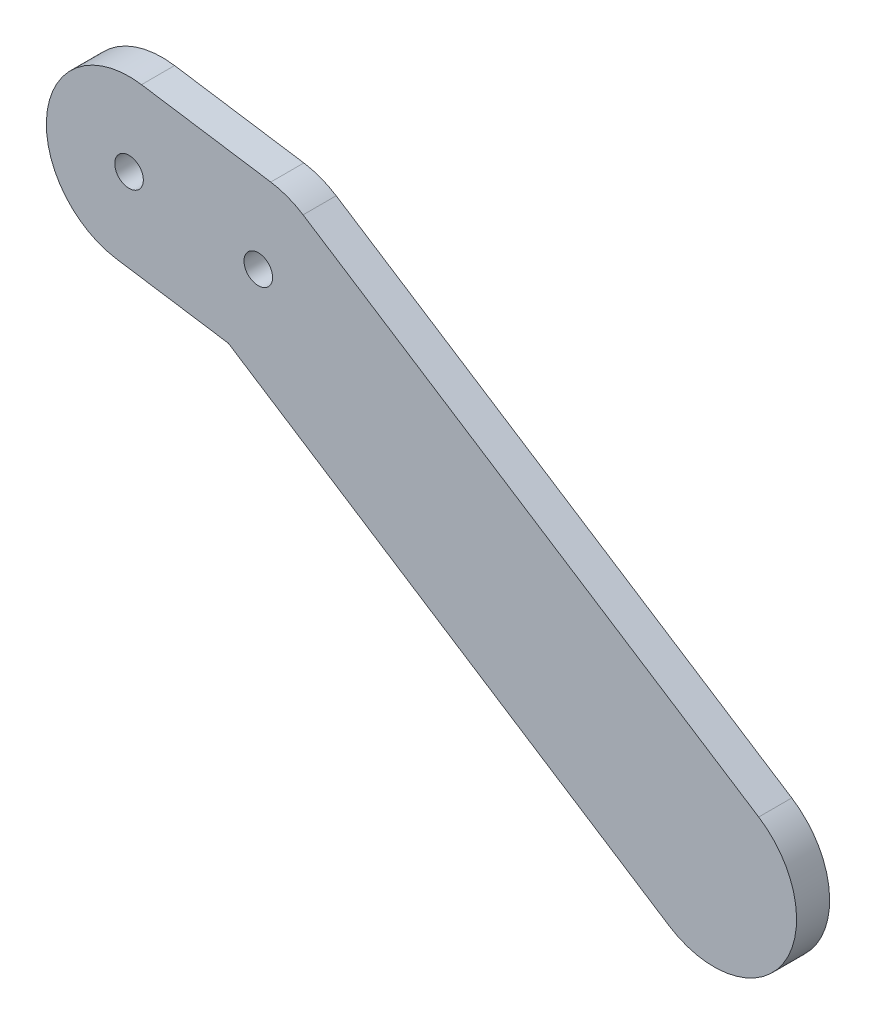
from build123d import *

# Parameters (mm, degrees)
SKETCH1_R           = 1.73
BOSS_EXTRUDE1_DEPTH = 2


with BuildPart() as part:
    # Sketch1 → Boss-Extrude1 (new body, symmetric)
    with BuildSketch(Plane.XY):
        with BuildLine():
            Line((-17.141234423, -7.500996555), (-3.621301313, -9.563286323))
            Line((-3.621301313, -9.563286323), (-5.418135156, -8.404987295))
            ThreePointArc((-5.418135156, -8.404987295), (-9.351968753, 3.541282315), (1.507927798, 9.885653937))
            Line((1.507927798, 9.885653937), (-14.125378827, 12.270311319))
            ThreePointArc((-14.125378827, 12.270311319), (-25.518960562, 3.89258518), (-17.141234423, -7.500996555))
        make_face()
        with Locations((-15.633306625, 2.384657382)):
            Circle(SKETCH1_R, mode=Mode.SUBTRACT)
        with BuildLine():
            Line((-3.621301313, -9.563286323), (-1.507927798, -9.885653937))
            ThreePointArc((-1.507927798, -9.885653937), (9.351968753, -3.541282315), (5.418135156, 8.404987295))
            ThreePointArc((5.418135156, 8.404987295), (3.541282315, 9.351968753), (1.507927798, 9.885653937))
            ThreePointArc((1.507927798, 9.885653937), (-9.351968753, 3.541282315), (-5.418135156, -8.404987295))
            Line((-5.418135156, -8.404987295), (-3.621301313, -9.563286323))
        make_face()
        Circle(SKETCH1_R, mode=Mode.SUBTRACT)
        with BuildLine():
            ThreePointArc((5.418135156, 8.404987295), (9.351968753, -3.541282315), (-1.507927798, -9.885653937))
            Line((-1.507927798, -9.885653937), (-3.621301313, -9.563286323))
            Line((-3.621301313, -9.563286323), (49.686174905, -43.927063542))
            ThreePointArc((49.686174905, -43.927063542), (63.509297356, -40.940211402), (60.522445216, -27.117088952))
            Line((60.522445216, -27.117088952), (5.418135156, 8.404987295))
        make_face()
    extrude(amount=BOSS_EXTRUDE1_DEPTH, both=True)


solid = part.part
